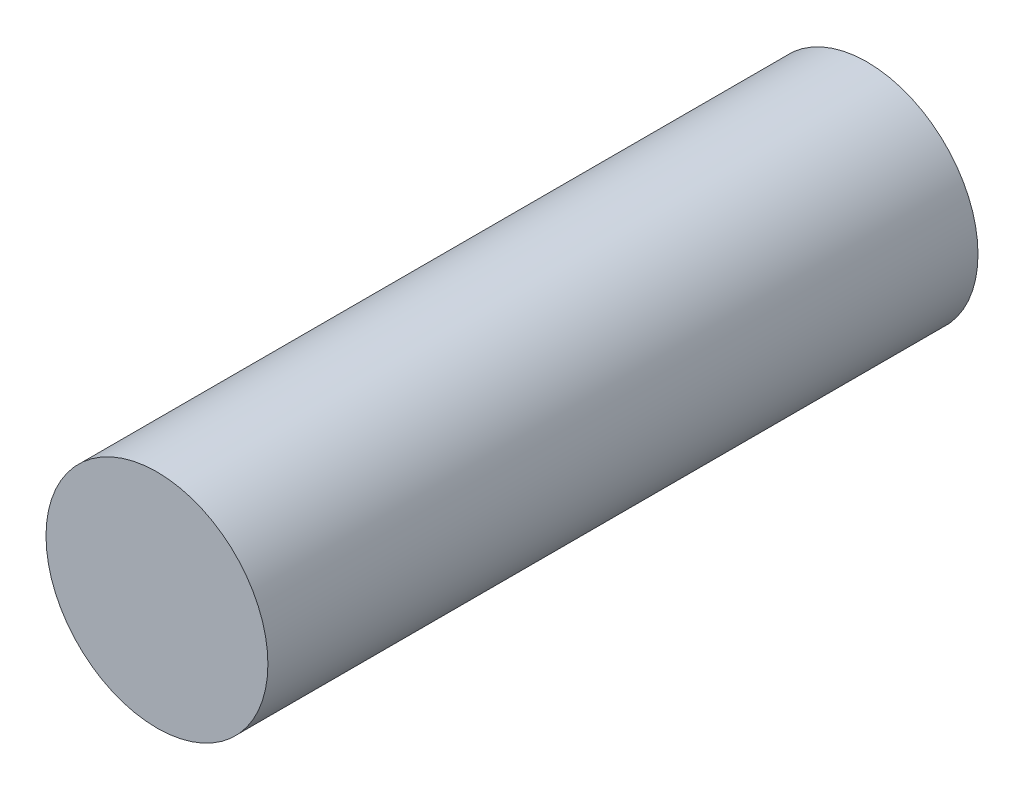
from build123d import *

# Parameters (mm, degrees)
SKETCH1_R           = 3.96875
BOSS_EXTRUDE1_DEPTH = 25.4


with BuildPart() as part:
    # Sketch1 → Boss-Extrude1 (new body)
    with BuildSketch(Plane.XY):
        Circle(SKETCH1_R)
    extrude(amount=BOSS_EXTRUDE1_DEPTH)


solid = part.part
